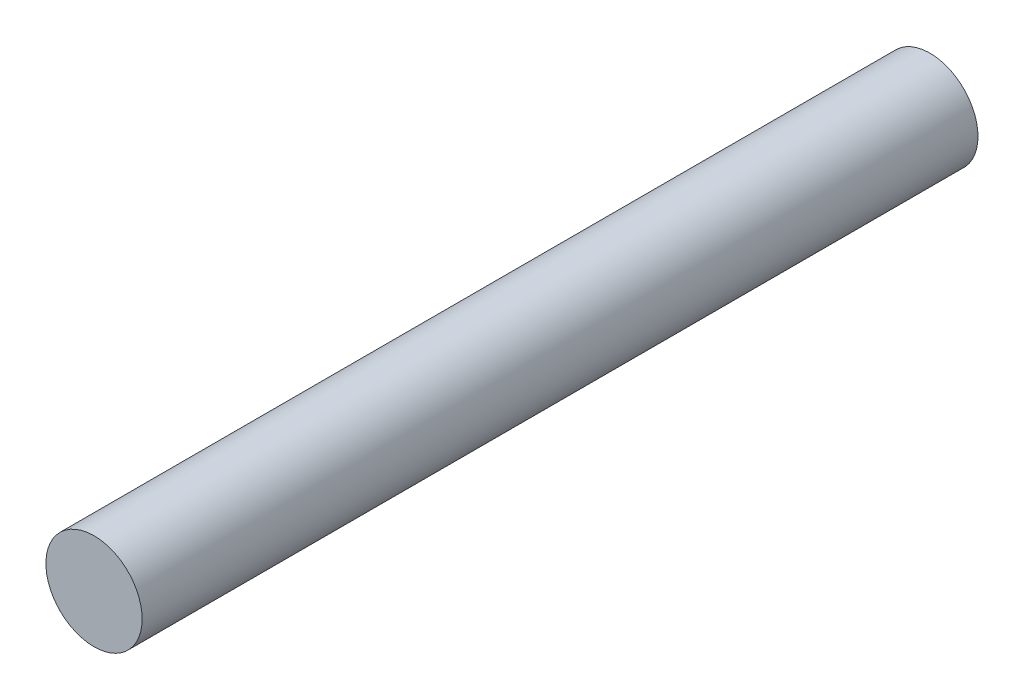
from build123d import *

# Parameters (mm, degrees)
SKETCH1_R           = 4
BOSS_EXTRUDE1_DEPTH = 69.5


with BuildPart() as part:
    # Sketch1 → Boss-Extrude1 (new body)
    with BuildSketch(Plane.XY):
        Circle(SKETCH1_R)
    extrude(amount=BOSS_EXTRUDE1_DEPTH)


solid = part.part
